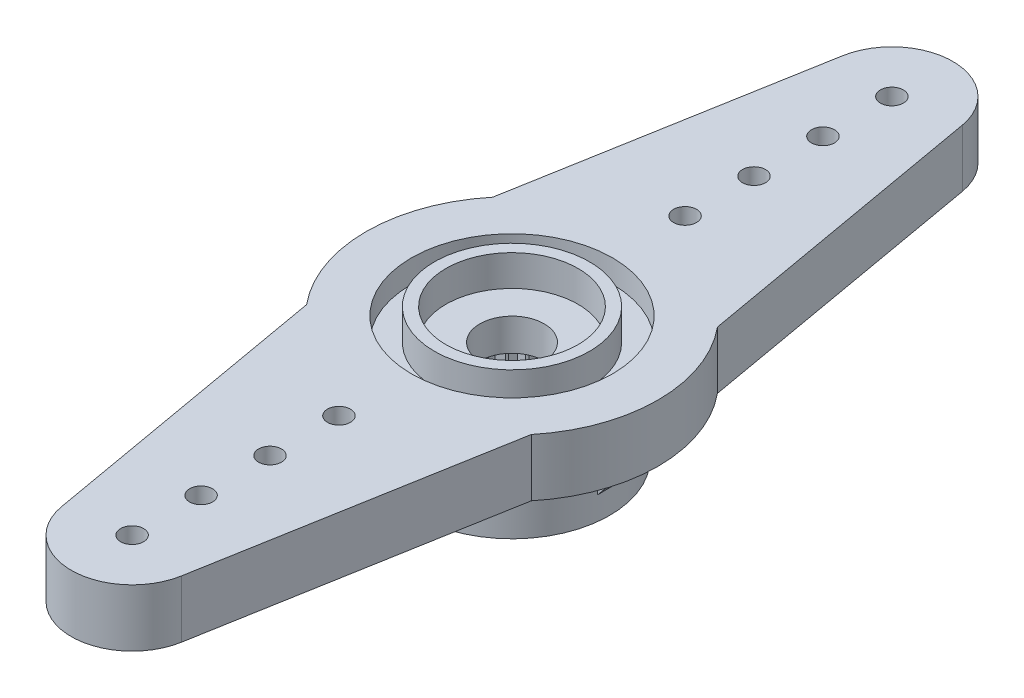
from build123d import *

# Parameters (mm, degrees)
BASES_R                     = 6.35
BASE_DEPTH                  = 5.4
TOPBORES_R                  = 1.4
TOP_BORE_DEPTH              = 11.478788098
HORN_HALF_DEPTH             = 2.5
HORNATTACHS_R               = 0.5
HORN_ATTACH_DEPTH           = 21.913031822
HA_LP_COUNT                 = 4
HA_LP_PITCH                 = 3
HORN_BODIES_COPY_1_SKETCH_R = 0.5
HORN_BODIES_COPY_1_DEPTH    = 21.913031822
HORN_BODIES_COPY_2_SKETCH_R = 0.5
HORN_BODIES_COPY_2_DEPTH    = 21.913031822
HORN_BODIES_COPY_3_SKETCH_R = 0.5
HORN_BODIES_COPY_3_DEPTH    = 21.913031822
TOOTH_DEPTH                 = 3
TOOTH_CP_COUNT              = 26
BOTTOMBORES_R               = 2.6
BOTTOM_BORE_DEPTH           = 3
HOLDINGSHAFTS_R             = 6.35
HOLDINGSHAFTS_R_2           = 4.25
HOLDING_SHAFT_DEPTH         = 2.9
RIB_DEPTH                   = 0.5
RIB_CP_COUNT                = 4
TOPCUTS_R                   = 4.375
TOP_CUT_DEPTH               = 1
TOPPOCKETCYLINDERS_R        = 3.375
TOPPOCKETCYLINDERS_R_2      = 2.875
TOP_POCKET_CYLINDER_DEPTH   = 1.35


with BuildPart() as part:
    # BaseS → BASE (new body)
    with BuildSketch(Plane(origin=(0, 0, 0), x_dir=(1, 0, 0), z_dir=(0, 1, 0))):
        with Locations(Location((0, 0, 0), (0, 0, 90))):
            Circle(BASES_R)
    extrude(amount=BASE_DEPTH)

    # TopBoreS → TOP BORE (cut, through all)
    with BuildSketch(Plane(origin=(0, 5.4, 0), x_dir=(1, 0, 0), z_dir=(0, 1, 0))):
        with Locations(Location((0, 0, 0), (0, 0, 270))):
            Circle(TOPBORES_R)
    extrude(amount=-TOP_BORE_DEPTH, mode=Mode.SUBTRACT)

    # HornHalfS → HORN HALF (add)
    with BuildSketch(Plane(origin=(0, 5.4, 0), x_dir=(1, 0, 0), z_dir=(0, 1, 0))):
        with BuildLine():
            Line((-2.609740545, 16.990167671), (-4.891612682, 4.049027706))
            ThreePointArc((-4.891612682, 4.049027706), (0, 6.35), (4.891612682, 4.049027706))
            Line((4.891612682, 4.049027706), (2.609740545, 16.990167671))
            ThreePointArc((2.609740545, 16.990167671), (0, 19.18), (-2.609740545, 16.990167671))
        make_face()
    horn_half = extrude(amount=-HORN_HALF_DEPTH)

    # HornAttachS → HORN ATTACH (cut, through all)
    with BuildSketch(Plane(origin=(0, 5.4, 0), x_dir=(1, 0, 0), z_dir=(0, 1, 0))):
        with Locations(Location((0, 16.53, 0), (0, 0, 270))):
            Circle(HORNATTACHS_R)
    horn_attach = extrude(amount=-HORN_ATTACH_DEPTH, mode=Mode.SUBTRACT)

    # HA LP: HORN ATTACH ×4
    with Locations(*[(0, 0, i * HA_LP_PITCH) for i in range(1, HA_LP_COUNT)]):
        add(horn_attach, mode=Mode.SUBTRACT)

    # HORN BODIES: HORN HALF, HORN ATTACH across plane
    add(horn_half.mirror(Plane.XY))
    add(horn_attach.mirror(Plane.XY), mode=Mode.SUBTRACT)

    # HORN BODIES copy 1 sketch → HORN BODIES copy 1 (cut, through all)
    with BuildSketch(Plane(origin=(0, 5.4, -3), x_dir=(1, 0, 0), z_dir=(0, 1, 0))):
        with Locations((0, -16.53)):
            Circle(HORN_BODIES_COPY_1_SKETCH_R)
    extrude(amount=-HORN_BODIES_COPY_1_DEPTH, mode=Mode.SUBTRACT)

    # HORN BODIES copy 2 sketch → HORN BODIES copy 2 (cut, through all)
    with BuildSketch(Plane(origin=(0, 5.4, -6), x_dir=(1, 0, 0), z_dir=(0, 1, 0))):
        with Locations((0, -16.53)):
            Circle(HORN_BODIES_COPY_2_SKETCH_R)
    extrude(amount=-HORN_BODIES_COPY_2_DEPTH, mode=Mode.SUBTRACT)

    # HORN BODIES copy 3 sketch → HORN BODIES copy 3 (cut, through all)
    with BuildSketch(Plane(origin=(0, 5.4, -9), x_dir=(1, 0, 0), z_dir=(0, 1, 0))):
        with Locations((0, -16.53)):
            Circle(HORN_BODIES_COPY_3_SKETCH_R)
    extrude(amount=-HORN_BODIES_COPY_3_DEPTH, mode=Mode.SUBTRACT)

    # ToothS → TOOTH (cut)
    with BuildSketch(Plane.XZ):
        with BuildLine():
            Line((0, -2.9), (0.262912611, -2.586672952))
            ThreePointArc((0.262912611, -2.586672952), (0, -2.6), (-0.262912611, -2.586672952))
            Line((-0.262912611, -2.586672952), (0, -2.9))
        make_face()
    tooth = extrude(amount=-TOOTH_DEPTH, mode=Mode.SUBTRACT)

    # TOOTH CP: TOOTH ×26 about axis
    tooth_cp_axis = Axis((0, 0, 0), (0, 1, 0))
    for i in range(1, TOOTH_CP_COUNT):
        add(tooth.rotate(tooth_cp_axis, i * 360 / TOOTH_CP_COUNT), mode=Mode.SUBTRACT)

    # BottomBoreS → BOTTOM BORE (cut)
    with BuildSketch(Plane(origin=(0, 0, 0), x_dir=(-1, 0, 0), z_dir=(0, -1, 0))):
        Circle(BOTTOMBORES_R)
    extrude(amount=-BOTTOM_BORE_DEPTH, mode=Mode.SUBTRACT)

    # HoldingShaftS → HOLDING SHAFT (cut)
    with BuildSketch(Plane.XZ):
        Circle(HOLDINGSHAFTS_R)
        with Locations(Location((0, 0, 0), (0, 0, 270))):
            Circle(HOLDINGSHAFTS_R_2, mode=Mode.SUBTRACT)
    extrude(amount=-HOLDING_SHAFT_DEPTH, mode=Mode.SUBTRACT)

    # RibS → RIB (add, symmetric)
    with BuildSketch(Plane.XY):
        Polygon((4.21, 1), (5.804289299, 2.9), (4.21, 2.9), (4.16, 2.9), (4.16, 1), align=None)
    rib = extrude(amount=RIB_DEPTH, both=True)

    # RIB CP: RIB ×4 about axis
    rib_cp_axis = Axis((0, 0, 0), (0, 1, 0))
    for i in range(1, RIB_CP_COUNT):
        add(rib.rotate(rib_cp_axis, i * 360 / RIB_CP_COUNT))

    # TopCutS → TOP CUT (cut)
    with BuildSketch(Plane(origin=(0, 5.4, 0), x_dir=(1, 0, 0), z_dir=(0, 1, 0))):
        with Locations(Location((0, 0, 0), (0, 0, 270))):
            Circle(TOPCUTS_R)
    extrude(amount=-TOP_CUT_DEPTH, mode=Mode.SUBTRACT)

    # TopPocketCylinderS → TOP POCKET CYLINDER (add)
    with BuildSketch(Plane(origin=(0, 4.4, 0), x_dir=(1, 0, 0), z_dir=(0, 1, 0))):
        with Locations(Location((0, 0, 0), (0, 0, 270))):
            Circle(TOPPOCKETCYLINDERS_R)
        with Locations(Location((0, 0, 0), (0, 0, 270))):
            Circle(TOPPOCKETCYLINDERS_R_2, mode=Mode.SUBTRACT)
    extrude(amount=TOP_POCKET_CYLINDER_DEPTH)


solid = part.part
